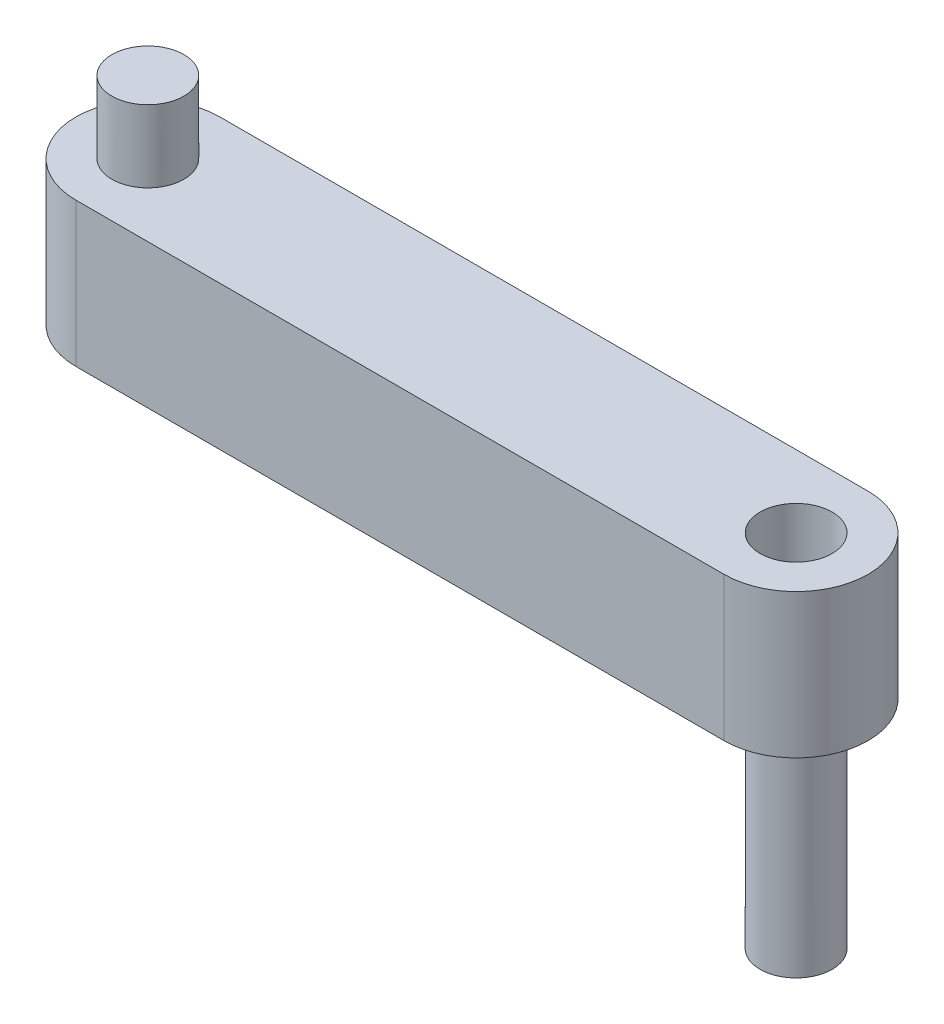
from build123d import *

# Parameters (mm, degrees)
BOSS_EXTRUDE1_DEPTH = 10
SKETCH2_R           = 2.5
BOSS_EXTRUDE2_DEPTH = 5
SKETCH3_R           = 2.5
BOSS_EXTRUDE3_DEPTH = 25
SKETCH5_R           = 2.5
CUT_EXTRUDE1_DEPTH  = 5
SKETCH4_R           = 2.5
CUT_EXTRUDE2_DEPTH  = 5


with BuildPart() as part:
    # Sketch1 → Boss-Extrude1 (new body)
    with BuildSketch(Plane(origin=(0, 0, 0), x_dir=(1, 0, 0), z_dir=(0, 1, 0))):
        with BuildLine():
            Line((-22.5, -5), (22.5, -5))
            ThreePointArc((22.5, -5), (27.5, 0), (22.5, 5))
            Line((22.5, 5), (-22.5, 5))
            ThreePointArc((-22.5, 5), (-27.5, 0), (-22.5, -5))
        make_face()
    extrude(amount=BOSS_EXTRUDE1_DEPTH)

    # Sketch2 → Boss-Extrude2 (add)
    with BuildSketch(Plane(origin=(0, 10, 0), x_dir=(1, 0, 0), z_dir=(0, 1, 0))):
        with Locations((-22.5, 0)):
            Circle(SKETCH2_R)
    extrude(amount=BOSS_EXTRUDE2_DEPTH)

    # Sketch3 → Boss-Extrude3 (add)
    with BuildSketch(Plane(origin=(0, 10, 0), x_dir=(1, 0, 0), z_dir=(0, 1, 0))):
        with Locations((22.5, 0)):
            Circle(SKETCH3_R)
    extrude(amount=-BOSS_EXTRUDE3_DEPTH)

    # Sketch5 → Cut-Extrude1 (cut)
    with BuildSketch(Plane.XZ):
        with Locations((-22.5, 0)):
            Circle(SKETCH5_R)
    extrude(amount=-CUT_EXTRUDE1_DEPTH, mode=Mode.SUBTRACT)

    # Sketch4 → Cut-Extrude2 (cut)
    with BuildSketch(Plane(origin=(0, 10, 0), x_dir=(1, 0, 0), z_dir=(0, 1, 0))):
        with Locations((22.5, 0)):
            Circle(SKETCH4_R)
    extrude(amount=-CUT_EXTRUDE2_DEPTH, mode=Mode.SUBTRACT)


solid = part.part
